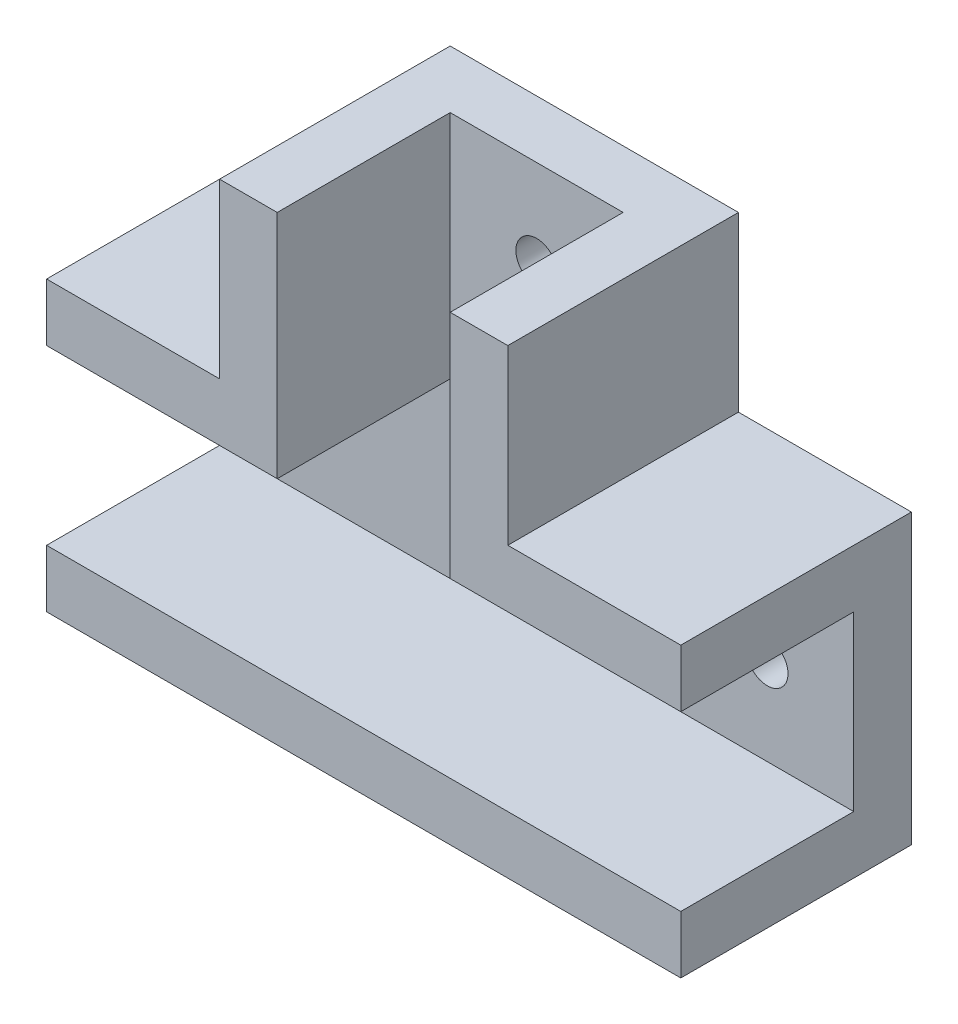
from build123d import *

# Parameters (mm, degrees)
BOSS_EXTRUDE1_DEPTH = 5
BOSS_EXTRUDE2_DEPTH = 20
SKETCH4_W           = 55
SKETCH4_H           = 5
BOSS_EXTRUDE3_DEPTH = 20
SKETCH6_R           = 1.8
CUT_EXTRUDE3_DEPTH  = 6


with BuildPart() as part:
    # Sketch1 → Boss-Extrude1 (new body)
    with BuildSketch(Plane.XY):
        Polygon((14.31372549, -4.264705882), (34.31372549, -4.264705882), (34.31372549, -19.264705882), (-20.68627451, -19.264705882), (-20.68627451, -4.264705882), (-0.68627451, -4.264705882), (-0.68627451, 15.735294118), (14.31372549, 15.735294118), align=None)
    extrude(amount=BOSS_EXTRUDE1_DEPTH)

    # Sketch2 → Boss-Extrude2 (add)
    with BuildSketch(Plane(origin=(0, 0, 0), x_dir=(-1, 0, 0), z_dir=(0, 0, -1))):
        Polygon((0.68627451, 15.735294118), (5.68627451, 15.735294118), (5.68627451, 0.735294118), (6.079970528, 0.735294118), (20.68627451, 0.735294118), (20.68627451, -4.264705882), (0.68627451, -4.264705882), align=None)
    boss_extrude2 = extrude(amount=-BOSS_EXTRUDE2_DEPTH)

    # Sketch4 → Boss-Extrude3 (add)
    with BuildSketch(Plane(origin=(0, 0, 0), x_dir=(-1, 0, 0), z_dir=(0, 0, -1))):
        with Locations((-6.81372549, -21.764705882)):
            Rectangle(SKETCH4_W, SKETCH4_H)
    extrude(amount=-BOSS_EXTRUDE3_DEPTH)

    # Mirror1: Boss-Extrude2 across plane
    add(boss_extrude2.mirror(Plane.ZY.offset(-6.81372549)))

    # Sketch6 → Cut-Extrude3 (cut, through all)
    with BuildSketch(Plane.XY.offset(5)):
        with Locations((6.81372549, 8.235294118)):
            Circle(SKETCH6_R)
        with Locations((-13.18627451, -11.764705882)):
            Circle(SKETCH6_R)
        with Locations((26.81372549, -11.764705882)):
            Circle(SKETCH6_R)
    extrude(amount=-CUT_EXTRUDE3_DEPTH, mode=Mode.SUBTRACT)


solid = part.part
